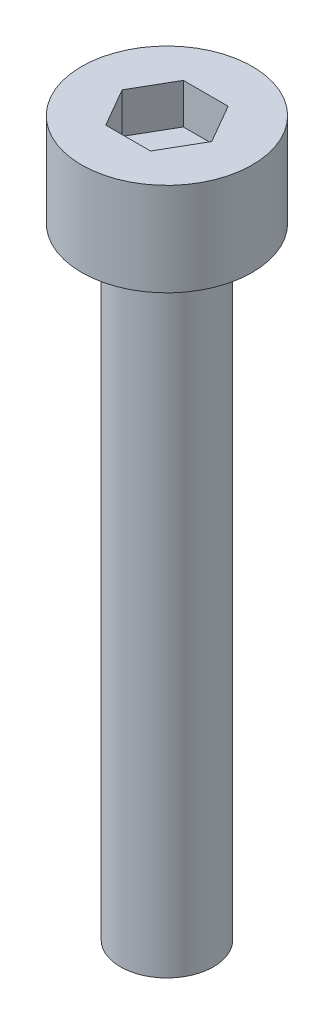
from build123d import *

# Parameters (mm, degrees)
SKETCH_1_R            = 2.75
EXTRUDE_248_DEPTH     = 3
CUT_EXTRUDE_378_DEPTH = 1.3
SKETCH_3_R            = 1.5
EXTRUDE_479_DEPTH     = 20


with BuildPart() as part:
    # 草图1 → Extrude 248 (new body)
    with BuildSketch(Plane(origin=(0, 0, 0), x_dir=(1, 0, 0), z_dir=(0, 1, 0))):
        Circle(SKETCH_1_R)
    extrude(amount=EXTRUDE_248_DEPTH)

    # 草图2 → Cut-Extrude 378 (cut)
    with BuildSketch(Plane(origin=(0, 3, 0), x_dir=(1, 0, 0), z_dir=(0, 1, 0))):
        Polygon((1.443375673, 0), (0.721687836, 1.25), (-0.721687836, 1.25), (-1.443375673, 0), (-0.721687836, -1.25), (0.721687836, -1.25), align=None)
    extrude(amount=-CUT_EXTRUDE_378_DEPTH, mode=Mode.SUBTRACT)

    # 草图3 → Extrude 479 (add)
    with BuildSketch(Plane.XZ):
        Circle(SKETCH_3_R)
    extrude(amount=EXTRUDE_479_DEPTH)


solid = part.part
